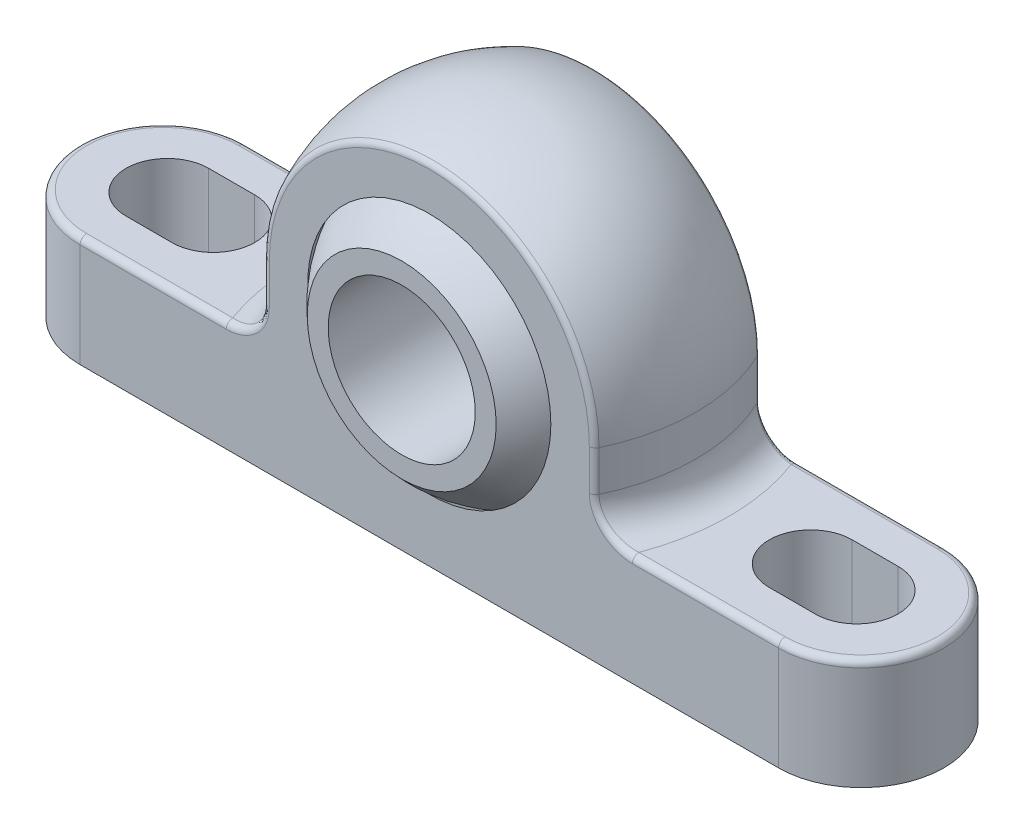
from build123d import *

# Parameters (mm, degrees)
EXTRUDE1_DEPTH          = 4.5
SKETCH3_OUTSIDE_W       = 59.374
SKETCH3_OUTSIDE_H       = 21.374
CUT_EXTRUDE1_DEPTH      = 32.18493225902536
CUT_EXTRUDE2_DEPTH      = 32.87867625859017
CUT_EXTRUDE2_DEPTH_BACK = 32.87867625859017
SKETCH6_OUTSIDE_W       = 28.706000000000003
SKETCH6_OUTSIDE_H       = 32.706
CUT_EXTRUDE3_DEPTH      = 32.87867625859017
CUT_EXTRUDE3_DEPTH_BACK = 32.87867625859017
SKETCH7_R               = 4
FILLET2_R               = 1.8
FILLET1_R               = 0.36


with BuildPart() as part:
    # Sketch1 → Extrude1 (new, symmetric)
    with BuildSketch(Plane.XY):
        with BuildLine():
            Line((-23.5, 0), (23.5, 0))
            Line((23.5, 0), (23.5, 6))
            Line((23.5, 6), (9.999999999999998, 5.9999999999999964))
            Line((9.999999999999998, 5.9999999999999964), (10.000000000000002, 10.000000000000002))
            ThreePointArc((10.000000000000002, 10.000000000000002), (6.1e-16, 20.000000000000004), (-10.000000000000002, 10.000000000000002))
            Line((-10.000000000000002, 10.000000000000002), (-9.999999999999991, 5.999999999999995))
            Line((-9.999999999999991, 5.999999999999995), (-23.5, 6))
            Line((-23.5, 6), (-23.5, 0))
        make_face()
    extrude(amount=EXTRUDE1_DEPTH, both=True)

    # Sketch2 → Cut-Revolve1 (revolve, cut)
    with BuildSketch(Plane.XY):
        with BuildLine():
            Line((15.000000000000004, 5.9999999999999964), (15.000000000000004, 25.000000000000007))
            Line((15.000000000000004, 25.000000000000007), (5.39e-15, 25.000000000000007))
            Line((5.39e-15, 25.000000000000007), (6e-15, 20.000000000000004))
            ThreePointArc((6e-15, 20.000000000000004), (7.071067811865478, 17.071067811865476), (10.000000000000002, 10.000000000000002))
            Line((10.000000000000002, 10.000000000000002), (9.999999999999998, 5.9999999999999964))
            Line((9.999999999999998, 5.9999999999999964), (15.000000000000004, 5.9999999999999964))
        make_face()
    revolve(axis=Axis((5.39e-15, 25.000000000000007, 0), (-1.08e-15, 1, 0)), mode=Mode.SUBTRACT)

    # Sketch3 outside → Cut-Extrude1 (cut, through all)
    # profile 1 of 3: a face of its own
    with BuildSketch(Plane(origin=(0, 0, 0), x_dir=(1, 0, 0), z_dir=(0, 1, 0))):
        Rectangle(SKETCH3_OUTSIDE_W, SKETCH3_OUTSIDE_H)
        with BuildLine():
            Line((-19.000000000000004, 4.500000000000003), (19.000000000000004, 4.499999999999999))
            ThreePointArc((19.000000000000004, 4.499999999999999), (23.500000000000004, 0), (19.000000000000004, -4.500000000000001))
            Line((19.000000000000004, -4.500000000000001), (-19.000000000000004, -4.500000000000003))
            ThreePointArc((-19.000000000000004, -4.500000000000003), (-23.500000000000007, 5.5e-16), (-19.000000000000004, 4.500000000000003))
        make_face(mode=Mode.SUBTRACT)
    # profile 2 of 3: a face of its own
    with BuildSketch(Plane(origin=(0, 0, 0), x_dir=(1, 0, 0), z_dir=(0, 1, 0))):
        with BuildLine():
            Line((-18.750000000000004, 2.2500000000000004), (-16.25, 2.2500000000000004))
            ThreePointArc((-16.25, 2.2500000000000004), (-14, 2e-16), (-16.25, -2.2499999999999996))
            Line((-16.25, -2.2499999999999996), (-18.750000000000004, -2.2499999999999996))
            ThreePointArc((-18.750000000000004, -2.2499999999999996), (-21.000000000000004, 4.9e-16), (-18.750000000000004, 2.2500000000000004))
        make_face()
    # profile 3 of 3: a face of its own
    with BuildSketch(Plane(origin=(0, 0, 0), x_dir=(1, 0, 0), z_dir=(0, 1, 0))):
        with BuildLine():
            Line((16.25, 2.2500000000000004), (18.750000000000004, 2.2500000000000004))
            ThreePointArc((18.750000000000004, 2.2500000000000004), (21.000000000000004, 2.2e-16), (18.750000000000004, -2.2499999999999996))
            Line((18.750000000000004, -2.2499999999999996), (16.25, -2.2499999999999996))
            ThreePointArc((16.25, -2.2499999999999996), (14, 4.9e-16), (16.25, 2.2500000000000004))
        make_face()
    extrude(amount=CUT_EXTRUDE1_DEPTH, mode=Mode.SUBTRACT)

    # Sketch4 → Cut-Revolve2 (revolve, cut)
    with BuildSketch(Plane.XY):
        with BuildLine():
            Line((0, 2.0000000000000018), (0, 18.000000000000004))
            ThreePointArc((0, 18.000000000000004), (8.000000000000002, 10.000000000000002), (0, 2.0000000000000018))
        make_face()
    revolve(axis=Axis((0, 2.0000000000000018, 0), (0, -1, 0)), mode=Mode.SUBTRACT)

    # Fillet2
    fillet2_edges = [part.edges().sort_by_distance(p)[0] for p in [
        (9.999999999999998, 5.9999999999999964, 0),
        (-9.999999999999945, 5.999999999999975, -8.9e-16),
    ]]
    fillet(fillet2_edges, radius=FILLET2_R)

    # Fillet1
    fillet1_edges = [part.edges().sort_by_distance(p)[0] for p in [
        (-14.954126877878789, 5.999999999999986, -4.500000000000001),
        (-14.954126877878785, 5.999999999999986, 4.499999999999999),
        (-8.93028554974583, 8.899999999999988, 4.5),
        (-8.93028554974583, 8.899999999999988, -4.5),
        (-9.546163849798285, 6.501316775429935, -4.5),
        (-9.54616384979828, 6.501316775429937, 4.5),
        (9.546163849889266, 6.501316775539111, 4.5),
        (9.546163849889268, 6.50131677553911, -4.5),
        (8.930285549745877, 8.899999999999997, -4.5),
        (-9.95e-15, 18.930285549745882, -4.5),
        (-9.95e-15, 18.930285549745882, 4.5),
        (8.930285549745877, 8.899999999999997, 4.5),
        (14.95412687787881, 5.999999999999997, -4.5),
        (14.95412687787881, 5.999999999999997, 4.499999999999999),
        (23.500000000000004, 6.000000000000006, 8.83e-15),
        (-23.500000000000007, 5.999999999999998, -2.61e-15),
    ]]
    fillet(fillet1_edges, radius=FILLET1_R)


with BuildPart() as body_2:
    # Sketch5 → Revolve1 (revolve)
    with BuildSketch(Plane.XY):
        with BuildLine():
            Line((0, 2.100000000000001), (0, 17.900000000000002))
            ThreePointArc((0, 17.900000000000002), (7.9, 10.000000000000002), (0, 2.100000000000001))
        make_face()
    revolve(axis=Axis((0, 2.100000000000001, 0), (0, -1, 0)))

    # Sketch6 outside → Cut-Extrude2 (cut, two sides: drawn at the far end of the back side and taken through both)
    with BuildSketch(Plane(origin=(0, 0, 0), x_dir=(0, 0, -1), z_dir=(1, 0, 0)).offset(-CUT_EXTRUDE2_DEPTH_BACK)):
        with Locations((0, 10.000000000000002)):
            Rectangle(SKETCH6_OUTSIDE_W, SKETCH6_OUTSIDE_H)
        Polygon((-6, 25.000000000000007), (6, 25.000000000000007), (5.999999999999995, 0), (-5.999999999999995, 0), align=None, mode=Mode.SUBTRACT)
    extrude(amount=CUT_EXTRUDE2_DEPTH + CUT_EXTRUDE2_DEPTH_BACK, mode=Mode.SUBTRACT)

    # Sketch7 → Cut-Extrude3 (cut, two sides: drawn at the far end of the back side and taken through both)
    with BuildSketch(Plane.XY.offset(-CUT_EXTRUDE3_DEPTH_BACK)):
        with Locations((0, 10.000000000000002)):
            Circle(SKETCH7_R)
    extrude(amount=CUT_EXTRUDE3_DEPTH + CUT_EXTRUDE3_DEPTH_BACK, mode=Mode.SUBTRACT)


solid = Compound([part.part, body_2.part])
